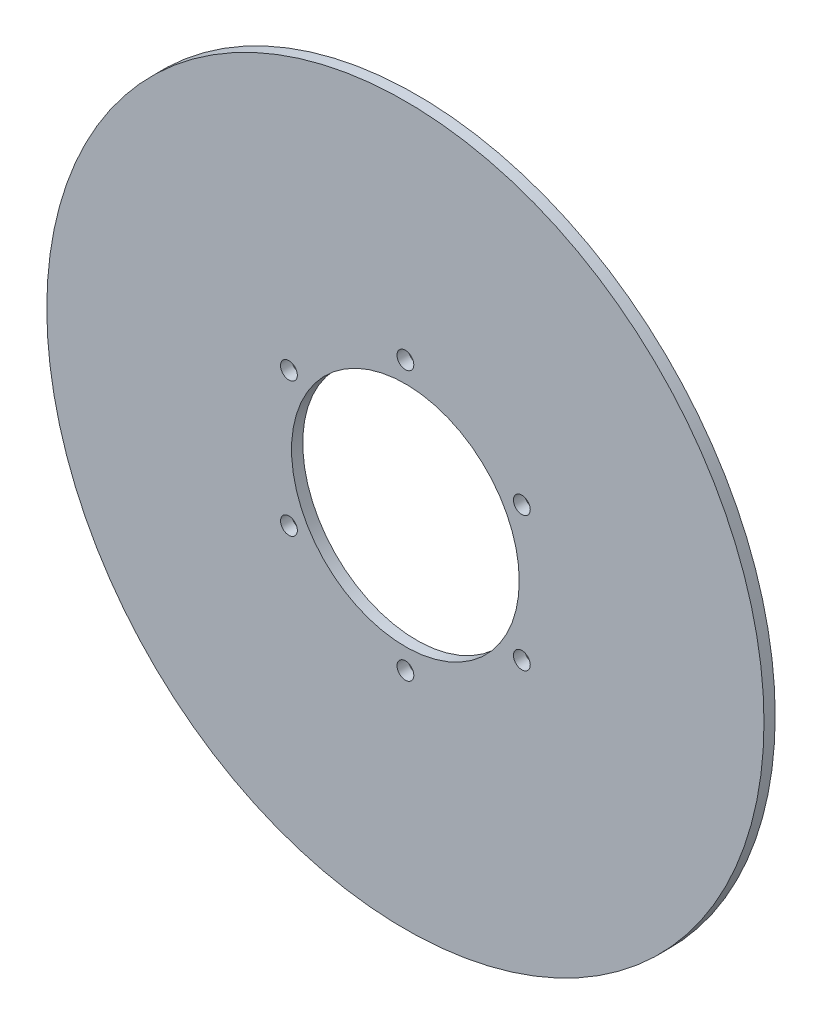
from build123d import *

# Parameters (mm, degrees)
SKETCH1_R           = 50.8
SKETCH1_R_2         = 16.129
BOSS_EXTRUDE1_DEPTH = 1.5875
CIRPATTERN1_COUNT   = 6


with BuildPart() as part:
    # Sketch1 → Boss-Extrude1 (new body)
    with BuildSketch(Plane.XY):
        Circle(SKETCH1_R)
        Circle(SKETCH1_R_2, mode=Mode.SUBTRACT)
    extrude(amount=BOSS_EXTRUDE1_DEPTH)

    # Sketch2 → 3/32 (0.09375) Diameter Hole1 (revolve, cut)
    with BuildSketch(Plane(origin=(0, 19.05, 1.5875), x_dir=(0, -1, 0), z_dir=(1, 0, 0))):
        Polygon((0, 0), (0, 26.115399675), (1.190625, 25.4), (1.190625, 0), align=None)
    f_3_32_0_09375_diameter_hole1 = revolve(axis=Axis((0, 19.05, 7.9375), (0, 0, -1)), mode=Mode.SUBTRACT)

    # CirPattern1: 3/32 (0.09375) Diameter Hole1 ×6 about axis
    cirpattern1_axis = Axis((0, 0, 0), (0, 0, 1))
    for i in range(1, CIRPATTERN1_COUNT):
        add(f_3_32_0_09375_diameter_hole1.rotate(cirpattern1_axis, i * 360 / CIRPATTERN1_COUNT), mode=Mode.SUBTRACT)


solid = part.part
